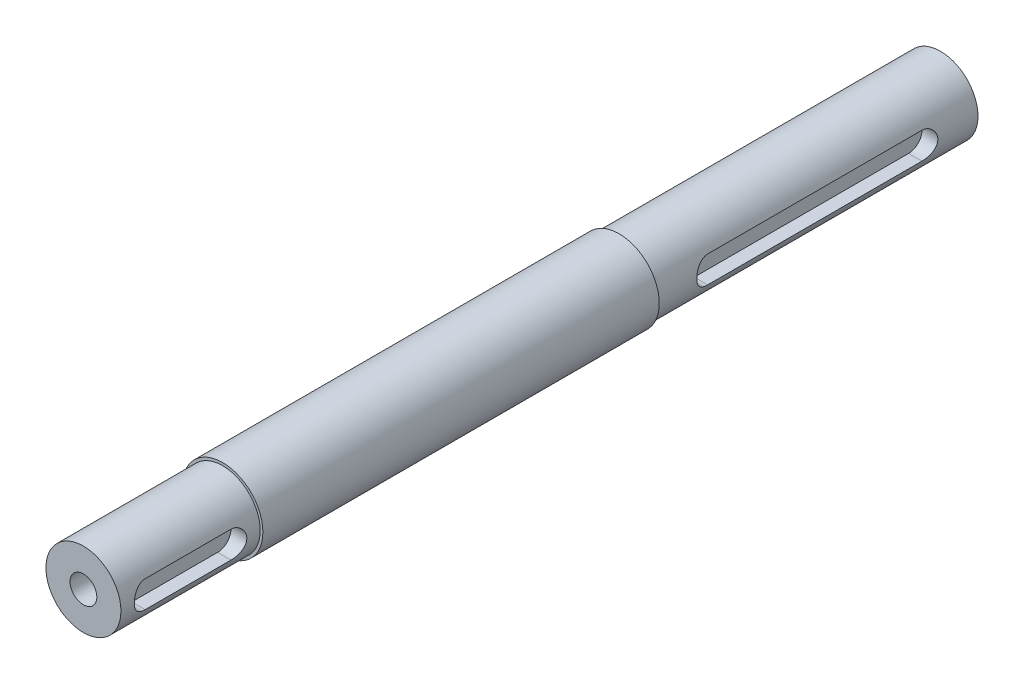
from build123d import *

# Parameters (mm, degrees)
ESQUISSE1_R                                   = 7
BOSS_EXTRU_1_DEPTH                            = 60
ESQUISSE3_R                                   = 7.5
BOSS_EXTRU_2_DEPTH                            = 62
ESQUISSE4_R                                   = 7.5
BOSS_EXTRU_3_DEPTH                            = 12
ESQUISSE5_R                                   = 7
BOSS_EXTRU_4_DEPTH                            = 26
ENL_V_MAT_EXTRU_1_DEPTH                       = 2.96
ENL_V_MAT_EXTRU_2_DEPTH                       = 2.96
TROU_POUR_TARAUDAGE_POUR_TROU_TARAUD_M6_D     = 5
TROU_POUR_TARAUDAGE_POUR_TROU_TARAUD_M6_DEPTH = 15
TROU_POUR_TARAUDAGE_POUR_TROU_TARAUD_M6_TIP   = 1.502151548
TROU_POUR_TARAUDAGE_POUR_TROU_TARAUD_2_D      = 5
TROU_POUR_TARAUDAGE_POUR_TROU_TARAUD_2_DEPTH  = 15
TROU_POUR_TARAUDAGE_POUR_TROU_TARAUD_2_TIP    = 1.502151548


with BuildPart() as part:
    # Esquisse1 → Boss.-Extru.1 (new body)
    with BuildSketch(Plane.XY):
        Circle(ESQUISSE1_R)
    extrude(amount=BOSS_EXTRU_1_DEPTH)

    # Esquisse3 → Boss.-Extru.2 (add)
    with BuildSketch(Plane.XY.offset(60)):
        Circle(ESQUISSE3_R)
    extrude(amount=BOSS_EXTRU_2_DEPTH)

    # Esquisse4 → Boss.-Extru.3 (add)
    with BuildSketch(Plane.XY.offset(122)):
        Circle(ESQUISSE4_R)
    extrude(amount=BOSS_EXTRU_3_DEPTH)

    # Esquisse5 → Boss.-Extru.4 (add)
    with BuildSketch(Plane.XY.offset(134)):
        Circle(ESQUISSE5_R)
    extrude(amount=BOSS_EXTRU_4_DEPTH)

    # Esquisse7 → Enlèv. mat.-Extru.1 (cut)
    with BuildSketch(Plane(origin=(7, 0, 0), x_dir=(0, 0, -1), z_dir=(1, 0, 0))):
        with BuildLine():
            Line((-155, 2.5), (-139, 2.5))
            ThreePointArc((-139, 2.5), (-136.5, 0), (-139, -2.5))
            Line((-139, -2.5), (-155, -2.5))
            ThreePointArc((-155, -2.5), (-157.5, 0), (-155, 2.5))
        make_face()
    extrude(amount=-ENL_V_MAT_EXTRU_1_DEPTH, mode=Mode.SUBTRACT)

    # Esquisse8 → Enlèv. mat.-Extru.2 (cut)
    with BuildSketch(Plane(origin=(7, 0, 0), x_dir=(0, 0, -1), z_dir=(1, 0, 0))):
        with BuildLine():
            Line((-10, -2.5), (-50, -2.5))
            ThreePointArc((-50, -2.5), (-52.5, 0), (-50, 2.5))
            Line((-50, 2.5), (-10, 2.5))
            ThreePointArc((-10, 2.5), (-7.5, 0), (-10, -2.5))
        make_face()
    extrude(amount=-ENL_V_MAT_EXTRU_2_DEPTH, mode=Mode.SUBTRACT)

    # Trou pour taraudage pour trou taraud_ M6
    with Locations(Plane(origin=(0, 0, 0), x_dir=(-1, 0, 0), z_dir=(0, 0, -1))):
        with Locations((0, 0)):
            Hole(TROU_POUR_TARAUDAGE_POUR_TROU_TARAUD_M6_D / 2, depth=TROU_POUR_TARAUDAGE_POUR_TROU_TARAUD_M6_DEPTH)
            with Locations((0, 0, -(TROU_POUR_TARAUDAGE_POUR_TROU_TARAUD_M6_DEPTH + TROU_POUR_TARAUDAGE_POUR_TROU_TARAUD_M6_TIP / 2))):  # 118° drill point
                Cone(0, TROU_POUR_TARAUDAGE_POUR_TROU_TARAUD_M6_D / 2, TROU_POUR_TARAUDAGE_POUR_TROU_TARAUD_M6_TIP, mode=Mode.SUBTRACT)

    # Trou pour taraudage pour trou taraud 2
    with Locations(Plane.XY.offset(160)):
        with Locations((0, 0)):
            Hole(TROU_POUR_TARAUDAGE_POUR_TROU_TARAUD_2_D / 2, depth=TROU_POUR_TARAUDAGE_POUR_TROU_TARAUD_2_DEPTH)
            with Locations((0, 0, -(TROU_POUR_TARAUDAGE_POUR_TROU_TARAUD_2_DEPTH + TROU_POUR_TARAUDAGE_POUR_TROU_TARAUD_2_TIP / 2))):  # 118° drill point
                Cone(0, TROU_POUR_TARAUDAGE_POUR_TROU_TARAUD_2_D / 2, TROU_POUR_TARAUDAGE_POUR_TROU_TARAUD_2_TIP, mode=Mode.SUBTRACT)


solid = part.part
